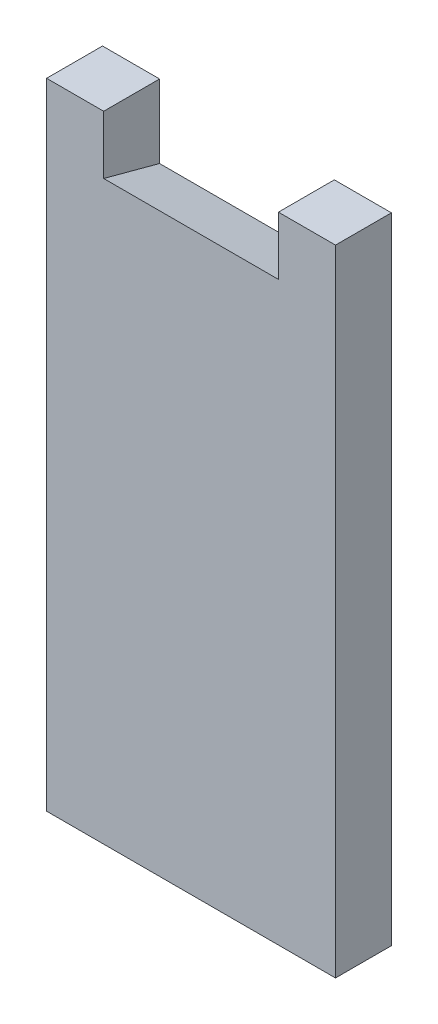
from build123d import *

# Parameters (mm, degrees)
EXTRUDE_1_DEPTH = 9.6
DRAFT_5_ANGLE   = -15


with BuildPart() as part:
    # 草图1 → 凸台-拉伸1 (new body)
    with BuildSketch(Plane.XY):
        Polygon((9.8, 0), (0, 0), (0, -108.97), (49.6, -108.97), (49.6, 0), (39.8, 0), (39.8, -10), (9.8, -10), align=None)
    extrude(amount=EXTRUDE_1_DEPTH)

    # 拔模5
    draft_5_faces = [part.faces().sort_by_distance(p)[0] for p in [
        (24.8, -10, 4.8),
    ]]
    draft(draft_5_faces, Plane.XY.offset(9.6), DRAFT_5_ANGLE)


solid = part.part
